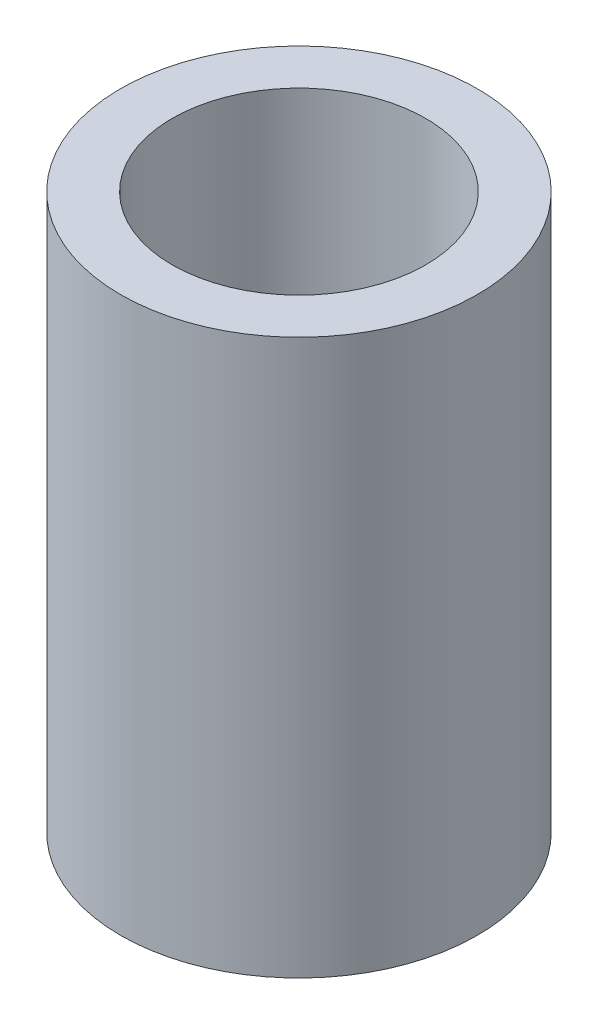
from build123d import *

# Parameters (mm, degrees)
SKETCH1_R           = 6.75
BOSS_EXTRUDE1_DEPTH = 21
SKETCH2_R           = 4.8
CUT_EXTRUDE1_DEPTH  = 10
CUT_EXTRUDE2_DEPTH  = 9


with BuildPart() as part:
    # Sketch1 → Boss-Extrude1 (new body)
    with BuildSketch(Plane(origin=(0, 0, 0), x_dir=(1, 0, 0), z_dir=(0, 1, 0))):
        Circle(SKETCH1_R)
    extrude(amount=BOSS_EXTRUDE1_DEPTH)

    # Sketch2 → Cut-Extrude1 (cut)
    with BuildSketch(Plane(origin=(0, 21, 0), x_dir=(1, 0, 0), z_dir=(0, 1, 0))):
        Circle(SKETCH2_R)
    extrude(amount=-CUT_EXTRUDE1_DEPTH, mode=Mode.SUBTRACT)

    # Sketch3 → Cut-Extrude2 (cut)
    with BuildSketch(Plane.XZ):
        with BuildLine():
            Line((-1.29747386, -1.098435971), (1.29747386, -1.098435971))
            ThreePointArc((1.29747386, -1.098435971), (0, 1.7), (-1.29747386, -1.098435971))
        make_face()
    extrude(amount=-CUT_EXTRUDE2_DEPTH, mode=Mode.SUBTRACT)


solid = part.part
